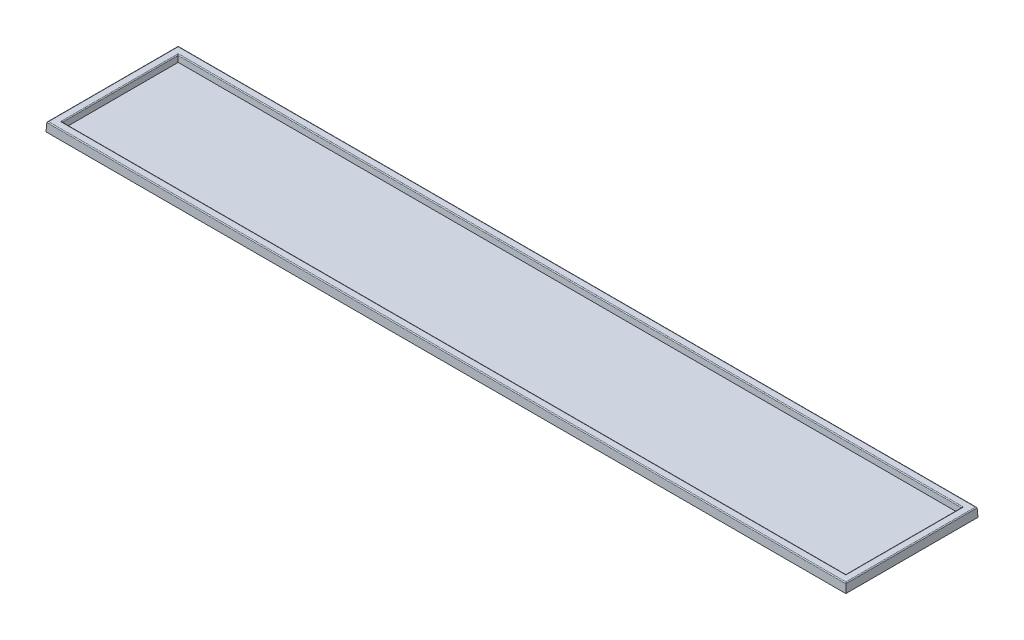
from build123d import *

# Parameters (mm, degrees)
SKETCH1_W           = 898.5
SKETCH1_H           = 148.5
BOSS_EXTRUDE1_DEPTH = 10
BOSS_EXTRUDE1_TAPER = 3
SKETCH2_W           = 880.451844414
SKETCH2_H           = 130.451844414
CUT_EXTRUDE1_DEPTH  = 7
CUT_EXTRUDE1_TAPER  = 5
FILLET1_R           = 1


with BuildPart() as part:
    # Sketch1 → Boss-Extrude1 (new body)
    with BuildSketch(Plane(origin=(0, 0, 0), x_dir=(1, 0, 0), z_dir=(0, 1, 0))):
        Rectangle(SKETCH1_W, SKETCH1_H)
    extrude(amount=BOSS_EXTRUDE1_DEPTH, taper=BOSS_EXTRUDE1_TAPER)

    # Sketch2 → Cut-Extrude1 (cut)
    with BuildSketch(Plane(origin=(0, 10, 0), x_dir=(1, 0, 0), z_dir=(0, 1, 0))):
        Rectangle(SKETCH2_W, SKETCH2_H)
    extrude(amount=-CUT_EXTRUDE1_DEPTH, taper=CUT_EXTRUDE1_TAPER, mode=Mode.SUBTRACT)

    # Fillet1
    fillet1_edges = [part.edges().sort_by_distance(p)[0] for p in [
        (-448.725922207, 10, 0),
        (0, 10, 73.725922207),
        (440.225922207, 10, 0),
        (0, 10, -65.225922207),
        (-440.225922207, 10, 0),
        (0, 10, 65.225922207),
        (448.725922207, 10, 0),
        (0, 10, -73.725922207),
    ]]
    fillet(fillet1_edges, radius=FILLET1_R)


solid = part.part
